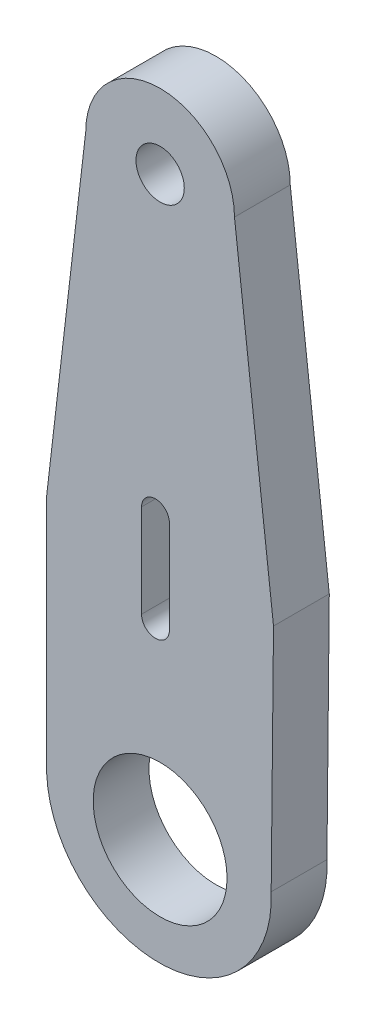
from build123d import *

# Parameters (mm, degrees)
MODEL_R             = 1.3
MODEL_R_2           = 3.6
BOSS_EXTRUDE1_DEPTH = 3


with BuildPart() as part:
    # Model → Boss-Extrude1 (new body)
    with BuildSketch(Plane.XY):
        with BuildLine():
            Line((54.4, 32.324975002), (54.4, 38.324975002))
            Line((54.4, 38.324975002), (56.5, 56.324876617))
            ThreePointArc((56.5, 56.324876617), (60.5, 60.324876617), (64.5, 56.324876617))
            Line((64.5, 56.324876617), (66.6, 38.324975002))
            Line((66.6, 38.324975002), (66.474361825, 25.879137217))
            ThreePointArc((66.474361825, 25.879137217), (60.71426202, 19.564875197), (54.4, 25.324975002))
            Line((54.4, 25.324975002), (54.4, 32.324975002))
        make_face()
        with Locations((60.5, 56.324876617)):
            Circle(MODEL_R, mode=Mode.SUBTRACT)
        with Locations((60.50005, 25.324984722)):
            Circle(MODEL_R_2, mode=Mode.SUBTRACT)
        with BuildLine():
            Line((59.5, 35.324934722), (59.5, 40.324934722))
            ThreePointArc((59.5, 40.324934722), (60.25, 41.074934722), (61, 40.324934722))
            Line((61, 40.324934722), (61, 35.324934722))
            ThreePointArc((61, 35.324934722), (60.25, 34.574934722), (59.5, 35.324934722))
        make_face(mode=Mode.SUBTRACT)
    extrude(amount=BOSS_EXTRUDE1_DEPTH)


solid = part.part
